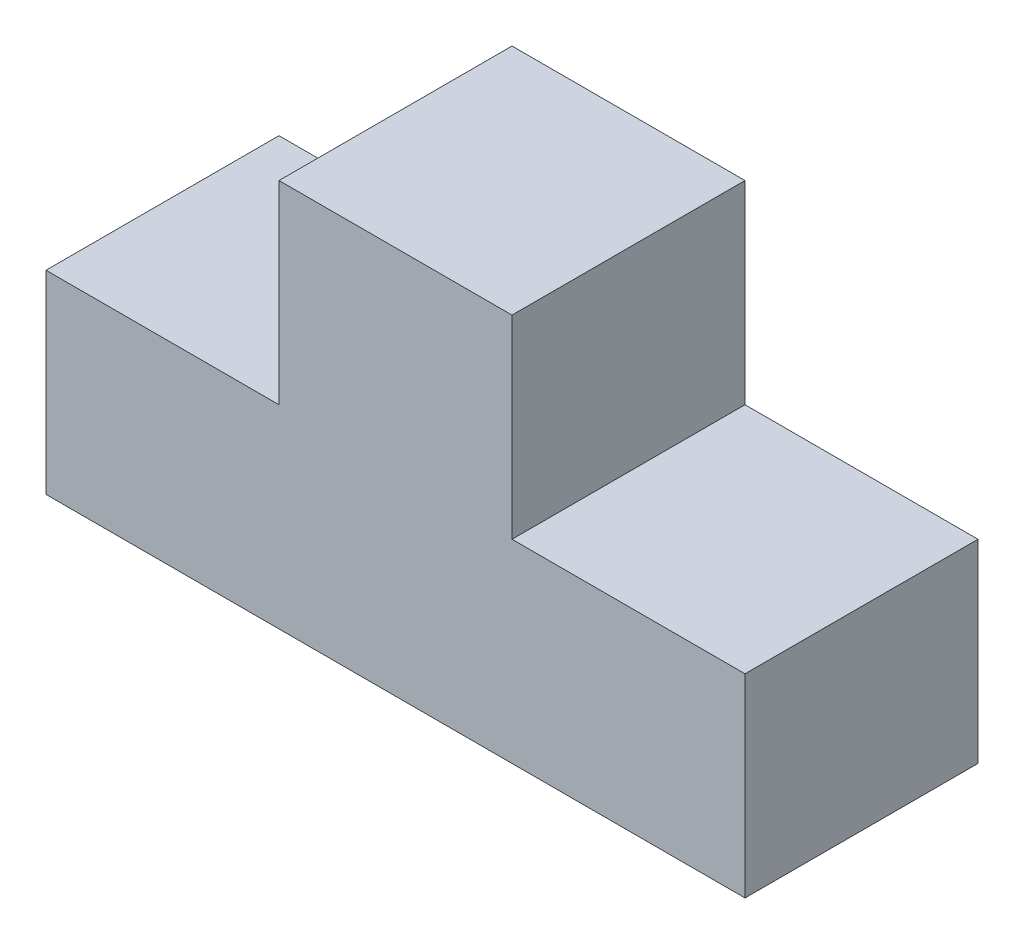
from build123d import *

# Parameters (mm, degrees)
BOSS_EXTRUDE1_DEPTH = 30


with BuildPart() as part:
    # Sketch1 → Boss-Extrude1 (new body)
    with BuildSketch(Plane.XY):
        Polygon((-45, 0), (45, 0), (45, 25), (15, 25), (15, 50), (-15, 50), (-15, 25), (-45, 25), align=None)
    extrude(amount=BOSS_EXTRUDE1_DEPTH)


solid = part.part
